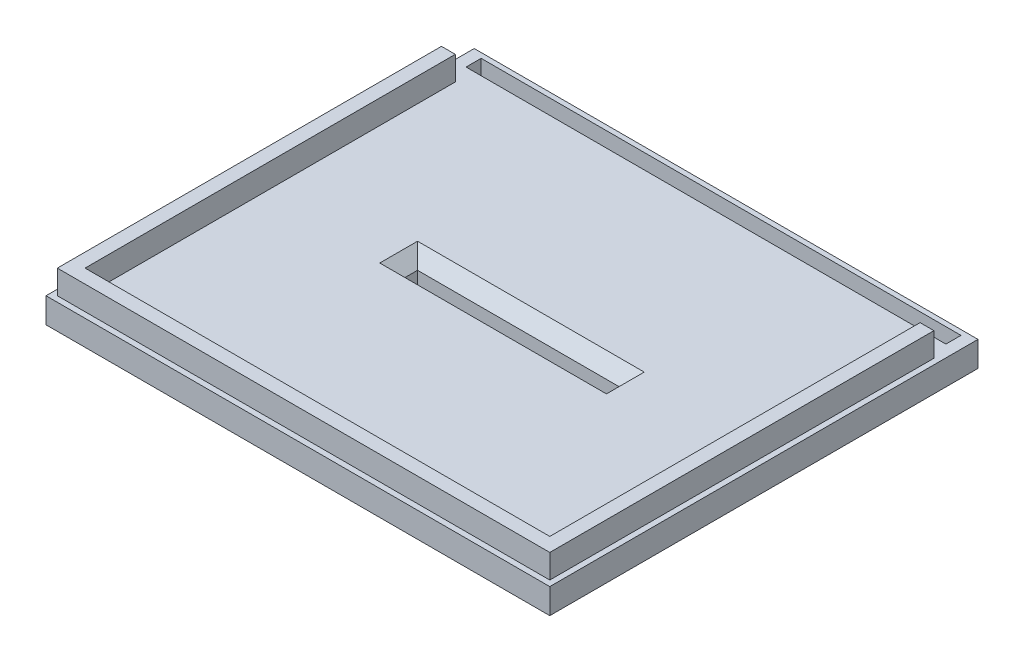
from build123d import *

# Parameters (mm, degrees)
CROQUIS1_W              = 200
CROQUIS1_H              = 170
SALIENTE_EXTRUIR1_DEPTH = 10
SALIENTE_EXTRUIR2_DEPTH = 19.5
CROQUIS2_W              = 169.5
CROQUIS2_H              = 6
CROQUIS2_W_2            = 5.25
CORTAR_EXTRUIR1_DEPTH   = 20
CROQUIS3_W              = 80
CROQUIS3_H              = 5
CORTAR_EXTRUIR2_DEPTH   = 10
CHAFL_N1_SIZE           = 5
CROQUIS4_W              = 92
CROQUIS4_H              = 14.5
CROQUIS4_W_2            = 86
CROQUIS4_H_2            = 8.5
SALIENTE_EXTRUIR3_DEPTH = 6
CROQUIS5_W              = 92
CROQUIS5_H              = 14.5
SALIENTE_EXTRUIR4_DEPTH = 2
CORTAR_EXTRUIR3_DEPTH   = 90


with BuildPart() as part:
    # Croquis1 → Saliente-Extruir1 (new body)
    with BuildSketch(Plane(origin=(0, 0, 0), x_dir=(1, 0, 0), z_dir=(0, 1, 0))):
        Rectangle(CROQUIS1_W, CROQUIS1_H)
    extrude(amount=SALIENTE_EXTRUIR1_DEPTH)

    # Croquis1_4 → Saliente-Extruir2 (add)
    with BuildSketch(Plane(origin=(0, 0, 0), x_dir=(1, 0, 0), z_dir=(0, 1, 0))):
        Polygon((97.75, 69.75), (97.75, -82.75), (-97.75, -82.75), (-97.75, 69.75), (-92.25, 69.75), (-92.25, -77.25), (92.25, -77.25), (92.25, 69.75), align=None)
    extrude(amount=SALIENTE_EXTRUIR2_DEPTH)

    # Croquis2 → Cortar-Extruir1 (cut)
    with BuildSketch(Plane(origin=(0, 10, 0), x_dir=(1, 0, 0), z_dir=(0, 1, 0))):
        with Locations((0, 80)):
            Rectangle(CROQUIS2_W, CROQUIS2_H)
        with Locations((-87.375, 80)):
            Rectangle(CROQUIS2_W_2, CROQUIS2_H)
        with Locations((-92.625, 80)):
            Rectangle(CROQUIS2_W_2, CROQUIS2_H)
        with Locations((87.375, 80)):
            Rectangle(CROQUIS2_W_2, CROQUIS2_H)
        with Locations((92.625, 80)):
            Rectangle(CROQUIS2_W_2, CROQUIS2_H)
    extrude(amount=-CORTAR_EXTRUIR1_DEPTH, mode=Mode.SUBTRACT)

    # Croquis3 → Cortar-Extruir2 (cut)
    with BuildSketch(Plane.XZ):
        Rectangle(CROQUIS3_W, CROQUIS3_H)
    extrude(amount=-CORTAR_EXTRUIR2_DEPTH, mode=Mode.SUBTRACT)

    # Chaflán1
    chafl_n1_edges = [part.edges().sort_by_distance(p)[0] for p in [
        (0, 10, -2.5),
        (-40, 10, 0),
        (0, 10, 2.5),
        (40, 10, 0),
    ]]
    chamfer(chafl_n1_edges, length=CHAFL_N1_SIZE)

    # Croquis4 → Saliente-Extruir3 (add)
    with BuildSketch(Plane.XZ):
        Rectangle(CROQUIS4_W, CROQUIS4_H)
        Rectangle(CROQUIS4_W_2, CROQUIS4_H_2, mode=Mode.SUBTRACT)
    extrude(amount=SALIENTE_EXTRUIR3_DEPTH)

    # Croquis5 → Saliente-Extruir4 (add)
    with BuildSketch(Plane.XZ.offset(6)):
        Rectangle(CROQUIS5_W, CROQUIS5_H)
    extrude(amount=SALIENTE_EXTRUIR4_DEPTH)

    # Croquis6 → Cortar-Extruir3 (cut)
    with BuildSketch(Plane(origin=(46, 0, 0), x_dir=(0, 0, -1), z_dir=(1, 0, 0))):
        Polygon((5.25, 0), (5.25, -6), (-5.25, -6), (-5.25, 0), (0, 0), align=None)
    extrude(amount=-CORTAR_EXTRUIR3_DEPTH, mode=Mode.SUBTRACT)


solid = part.part
